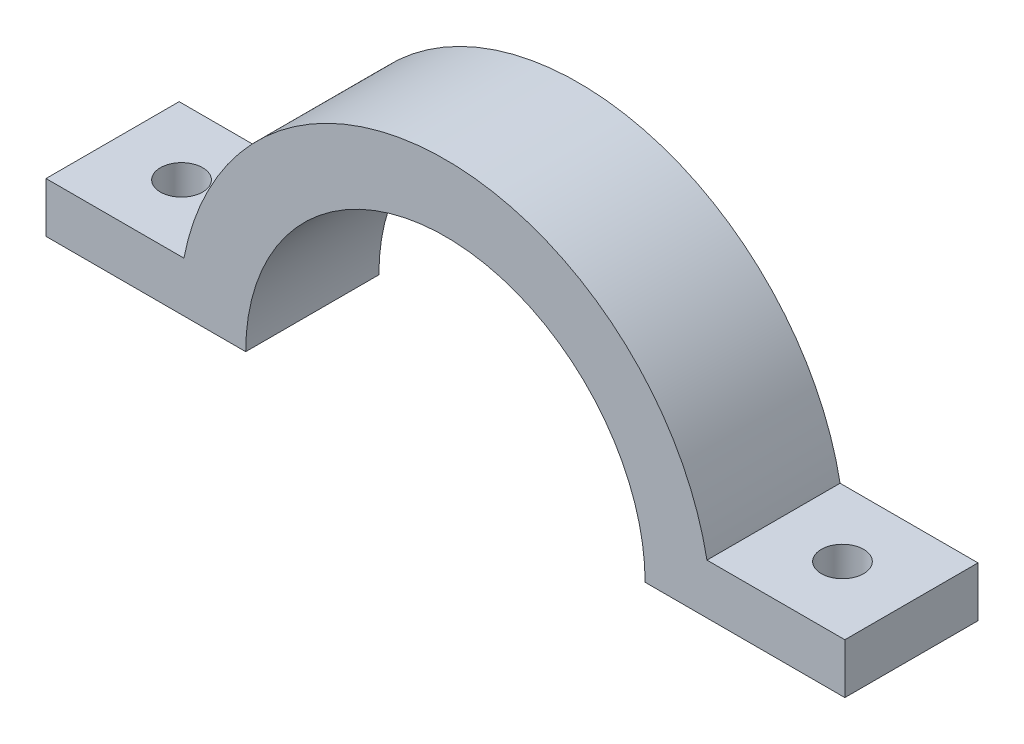
from build123d import *

# Parameters (mm, degrees)
BOSS_EXTRUDE1_DEPTH = 10
SKETCH2_R           = 1.5875
CUT_EXTRUDE1_DEPTH  = 3.765696


with BuildPart() as part:
    # Sketch1 → Boss-Extrude1 (new body)
    with BuildSketch(Plane.XY):
        with BuildLine():
            Line((-20, 0), (-15, 0))
            ThreePointArc((-15, 0), (0, 15), (15, 0))
            Line((15, 0), (20, 0))
            Line((20, 0), (30, 0))
            Line((30, 0), (30, 3.765695973))
            Line((30, 3.765695973), (19.642289425, 3.765695973))
            ThreePointArc((19.642289425, 3.765695973), (0, 20), (-19.642289425, 3.765695973))
            Line((-19.642289425, 3.765695973), (-30, 3.765695973))
            Line((-30, 3.765695973), (-30, 0))
            Line((-30, 0), (-20, 0))
        make_face()
    extrude(amount=BOSS_EXTRUDE1_DEPTH)

    # Sketch2 → Cut-Extrude1 (cut)
    with BuildSketch(Plane(origin=(0, 3.765695973, 0), x_dir=(1, 0, 0), z_dir=(0, 1, 0))):
        with Locations((24.821144712, -5)):
            Circle(SKETCH2_R)
    cut_extrude1 = extrude(amount=-CUT_EXTRUDE1_DEPTH, mode=Mode.SUBTRACT)

    # Mirror1: Cut-Extrude1 across plane
    add(cut_extrude1.mirror(Plane.ZY), mode=Mode.SUBTRACT)


solid = part.part
